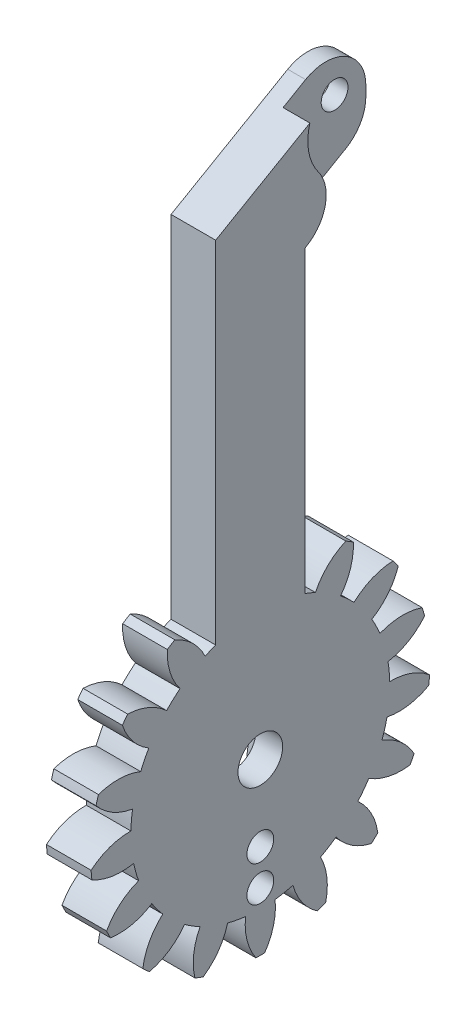
from build123d import *

# Parameters (mm, degrees)
BASPROSKE_W             = 10
BASPROSKE_H             = 19
TOOTHCUT_DEPTH          = 29.670542374
TEETHCUTS_COUNT         = 17
TEETHCUTS_ANGLE         = 338.823529412
BORSKE_R                = 2.5
BORE_DEPTH              = 50.0019304
CUT_EXTRUDE1_DEPTH      = 20
CUT_EXTRUDE1_DEPTH_BACK = 20
SKETCH1_W               = 10
SKETCH1_H               = 40
BOSS_EXTRUDE1_DEPTH     = 5
SKETCH5_R               = 1.5
CUT_EXTRUDE5_DEPTH      = 68.251600881
FILLET2_R               = 4.5
CUT_EXTRUDE7_DEPTH      = 3
CUT_EXTRUDE8_DEPTH      = 2
SKETCH8_R               = 1.5
CUT_EXTRUDE9_DEPTH      = 64.982759166
FILLET3_R               = 4.5


with BuildPart() as part:
    # BasProSke → Base-Revolve (revolve)
    with BuildSketch(Plane(origin=(0, 0, 0), x_dir=(1, 0, 0), z_dir=(0, 1, 0))):
        with Locations((5, 9.5)):
            Rectangle(BASPROSKE_W, BASPROSKE_H)
    revolve(axis=Axis((-10, 0, 0), (1, 0, 0)))

    # TooCutSke → ToothCut (cut, through all)
    with BuildSketch(Plane(origin=(0, 0, 0), x_dir=(0, 0, -1), z_dir=(1, 0, 0))):
        with BuildLine():
            ThreePointArc((1.020352389, 14.463052306), (0, 14.499), (-1.020352389, 14.463052306))
            ThreePointArc((-1.020352389, 14.463052306), (-1.632621885, 16.804485203), (-3.026143023, 18.783192049))
            ThreePointArc((-3.026143023, 18.783192049), (0, 19.0254), (3.026143023, 18.783192049))
            ThreePointArc((3.026143023, 18.783192049), (1.632621885, 16.804485203), (1.020352389, 14.463052306))
        make_face()
    toothcut = extrude(amount=TOOTHCUT_DEPTH, mode=Mode.SUBTRACT)

    # TeethCuts: ToothCut ×17 about axis
    teethcuts_axis = Axis((-10, 0, 0), (1, 0, 0))
    for i in range(1, TEETHCUTS_COUNT):
        add(toothcut.rotate(teethcuts_axis, i * TEETHCUTS_ANGLE / (TEETHCUTS_COUNT - 1)), mode=Mode.SUBTRACT)

    # BorSke → Bore (cut, symmetric)
    with BuildSketch(Plane(origin=(0, 0, 0), x_dir=(0, 0, -1), z_dir=(1, 0, 0))):
        Circle(BORSKE_R)
    extrude(amount=BORE_DEPTH, both=True, mode=Mode.SUBTRACT)

    # Sketch1 → Cut-Extrude1 (cut, two sides: drawn at the far end of the back side and taken through both)
    with BuildSketch(Plane.XY.offset(-CUT_EXTRUDE1_DEPTH_BACK)):
        Rectangle(SKETCH1_W, SKETCH1_H)
    extrude(amount=CUT_EXTRUDE1_DEPTH + CUT_EXTRUDE1_DEPTH_BACK, mode=Mode.SUBTRACT)

    # Sketch4 → Boss-Extrude1 (add)
    with BuildSketch(Plane(origin=(10, 0, 0), x_dir=(0, 0, -1), z_dir=(1, 0, 0))):
        with BuildLine():
            Line((5, 0), (5, 47.113248654))
            Line((5, 47.113248654), (14.820508076, 52.783121635))
            Line((14.820508076, 52.783121635), (14.820508076, 64.330127019))
            Line((14.820508076, 64.330127019), (-5, 52.886751346))
            Line((-5, 52.886751346), (-5, 0))
            Line((-5, 0), (-2.5, 0))
            ThreePointArc((-2.5, 0), (0, 2.5), (2.5, 0))
            Line((2.5, 0), (5, 0))
        make_face()
    extrude(amount=-BOSS_EXTRUDE1_DEPTH)

    # Sketch5 → Cut-Extrude5 (cut, through all)
    with BuildSketch(Plane.ZY.offset(-5)):
        with Locations((-11.320508076, 57.330127019)):
            Circle(SKETCH5_R)
    extrude(amount=-CUT_EXTRUDE5_DEPTH, mode=Mode.SUBTRACT)

    # Fillet2
    fillet2_edges = [part.edges().sort_by_distance(p)[0] for p in [
        (7.5, 52.783121635, -14.820508076),
        (7.5, 64.330127019, -14.820508076),
    ]]
    fillet(fillet2_edges, radius=FILLET2_R)

    # Sketch7 → Cut-Extrude7 (cut)
    with BuildSketch(Plane(origin=(10, 0, 0), x_dir=(0, 0, -1), z_dir=(1, 0, 0))):
        with BuildLine():
            Line((17.722340532, 67.954429941), (8.320508076, 62.526279442))
            ThreePointArc((8.320508076, 62.526279442), (6.124355653, 54.330127019), (14.320508076, 52.133974596))
            Line((14.320508076, 52.133974596), (23.722340532, 57.562125096))
            Line((23.722340532, 57.562125096), (17.722340532, 67.954429941))
        make_face()
    extrude(amount=-CUT_EXTRUDE7_DEPTH, mode=Mode.SUBTRACT)

    # Sketch2 → Cut-Extrude8 (cut)
    with BuildSketch(Plane.ZY.offset(-5)):
        with BuildLine():
            Line((2, -14.5), (4, 0))
            ThreePointArc((4, 0), (-0.279231906, 3.99024179), (-3.961014771, -0.557101411))
            Line((-3.961014771, -0.557101411), (-2, -14.5))
            ThreePointArc((-2, -14.5), (0, -16.5), (2, -14.5))
        make_face()
    extrude(amount=-CUT_EXTRUDE8_DEPTH, mode=Mode.SUBTRACT)

    # Sketch8 → Cut-Extrude9 (cut, through all)
    with BuildSketch(Plane.ZY.offset(-7)):
        with Locations((0, -8.45)):
            Circle(SKETCH8_R)
        with Locations((0, -12.45)):
            Circle(SKETCH8_R)
    extrude(amount=-CUT_EXTRUDE9_DEPTH, mode=Mode.SUBTRACT)

    # Fillet3
    fillet3_edges = [part.edges().sort_by_distance(p)[0] for p in [
        (8.5, 51.449252752, -12.5101794),
    ]]
    fillet(fillet3_edges, radius=FILLET3_R)


solid = part.part
